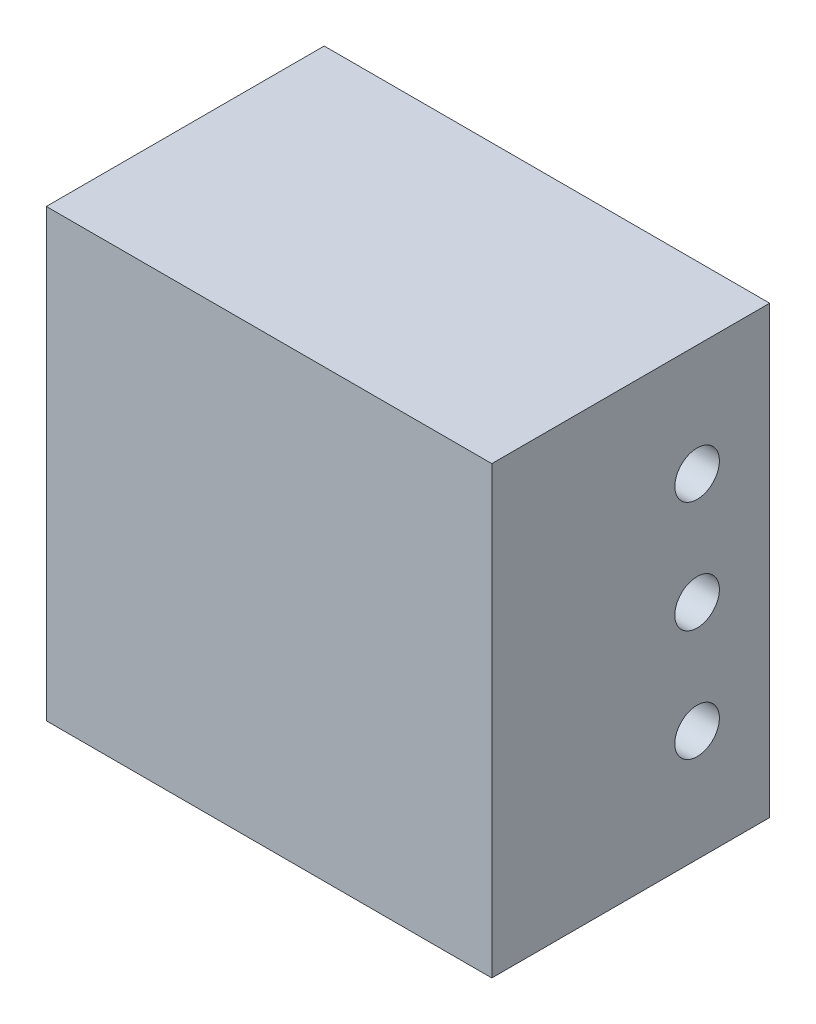
from build123d import *

# Parameters (mm, degrees)
SKETCH1_W               = 82.75
SKETCH1_H               = 127
BOSS_EXTRUDE1_DEPTH     = 127
SKETCH2_R               = 6.35
CUT_EXTRUDE1_DEPTH      = 1
CUT_EXTRUDE1_DEPTH_BACK = 127
SKETCH3_W               = 28.753041512
SKETCH3_H               = 129.689601996
CUT_EXTRUDE2_DEPTH      = 127
SKETCH6_W               = 3.210142998
SKETCH6_H               = 200
CUT_EXTRUDE3_DEPTH      = 128


with BuildPart() as part:
    # Sketch1 → Boss-Extrude1 (new body)
    with BuildSketch(Plane(origin=(0, 0, 0), x_dir=(0, 0, -1), z_dir=(1, 0, 0))):
        Rectangle(SKETCH1_W, SKETCH1_H)
    extrude(amount=BOSS_EXTRUDE1_DEPTH)

    # Sketch2 → Cut-Extrude1 (cut, two sides)
    with BuildSketch(Plane(origin=(127, 0, 0), x_dir=(0, 0, -1), z_dir=(1, 0, 0))) as cut_extrude1_sk:
        with Locations((20.6875, 31.75)):
            Circle(SKETCH2_R)
        with Locations((20.6875, -31.75)):
            Circle(SKETCH2_R)
        with Locations((20.6875, 0)):
            Circle(SKETCH2_R)
    extrude(amount=CUT_EXTRUDE1_DEPTH, mode=Mode.SUBTRACT)
    extrude(cut_extrude1_sk.sketch, amount=-CUT_EXTRUDE1_DEPTH_BACK, mode=Mode.SUBTRACT)

    # Sketch3 → Cut-Extrude2 (cut)
    with BuildSketch(Plane(origin=(127, 0, 0), x_dir=(0, 0, -1), z_dir=(1, 0, 0))):
        with Locations((-53.011520756, -1.344800998)):
            Rectangle(SKETCH3_W, SKETCH3_H)
    extrude(amount=-CUT_EXTRUDE2_DEPTH, mode=Mode.SUBTRACT)

    # Sketch6 → Cut-Extrude3 (cut, through all)
    with BuildSketch(Plane(origin=(127, 0, 0), x_dir=(0, 0, -1), z_dir=(1, 0, 0))):
        with Locations((-39.450071499, -36.5)):
            Rectangle(SKETCH6_W, SKETCH6_H)
    extrude(amount=-CUT_EXTRUDE3_DEPTH, mode=Mode.SUBTRACT)


solid = part.part
